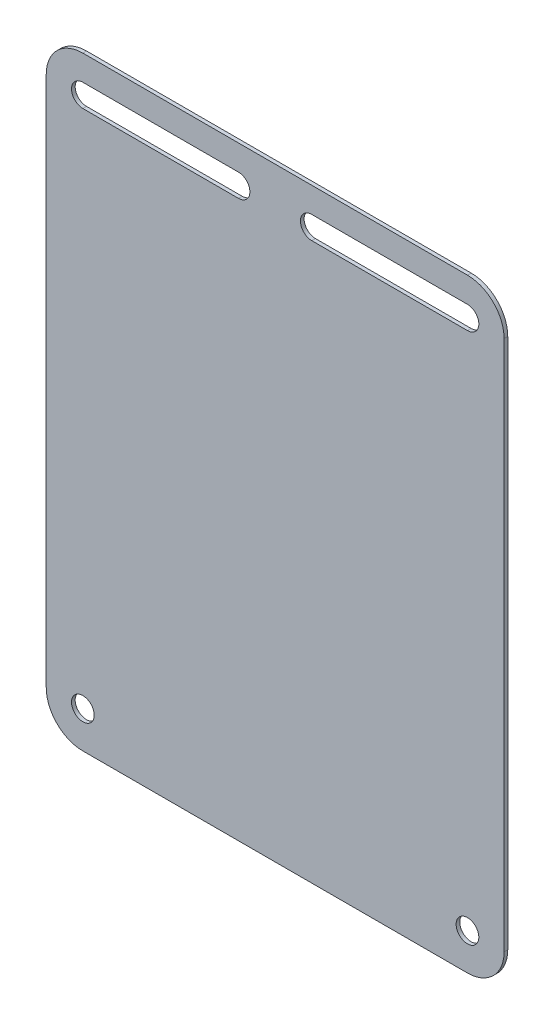
from build123d import *

# Parameters (mm, degrees)
SKETCH_1_W      = 125
SKETCH_1_H      = 165
SKETCH_1_R      = 3.1
EXTRUDE_1_DEPTH = 1
FILLET_1_R      = 10


with BuildPart() as part:
    # 草图1 → 凸台-拉伸1 (new body)
    with BuildSketch(Plane.XY):
        with Locations((55.043478261, -55.576086957)):
            Rectangle(SKETCH_1_W, SKETCH_1_H)
        with Locations((107.543478261, -128.076086957)):
            Circle(SKETCH_1_R, mode=Mode.SUBTRACT)
        with Locations((2.543478261, -128.076086957)):
            Circle(SKETCH_1_R, mode=Mode.SUBTRACT)
        with BuildLine():
            Line((107.543478261, 20.023913043), (65.043478261, 20.023913043))
            ThreePointArc((65.043478261, 20.023913043), (61.943478261, 16.923913043), (65.043478261, 13.823913043))
            Line((65.043478261, 13.823913043), (107.543478261, 13.823913043))
            ThreePointArc((107.543478261, 13.823913043), (110.643478261, 16.923913043), (107.543478261, 20.023913043))
        make_face(mode=Mode.SUBTRACT)
        with BuildLine():
            Line((45.043478261, 20.023913043), (2.543478261, 20.023913043))
            ThreePointArc((2.543478261, 20.023913043), (-0.556521739, 16.923913043), (2.543478261, 13.823913043))
            Line((2.543478261, 13.823913043), (45.043478261, 13.823913043))
            ThreePointArc((45.043478261, 13.823913043), (48.143478261, 16.923913043), (45.043478261, 20.023913043))
        make_face(mode=Mode.SUBTRACT)
    extrude(amount=EXTRUDE_1_DEPTH)

    # 圆角1
    fillet_1_edges = [part.edges().sort_by_distance(p)[0] for p in [
        (-7.456521739, 26.923913043, 0.5),
        (117.543478261, 26.923913043, 0.5),
        (117.543478261, -138.076086957, 0.5),
        (-7.456521739, -138.076086957, 0.5),
    ]]
    fillet(fillet_1_edges, radius=FILLET_1_R)


solid = part.part
